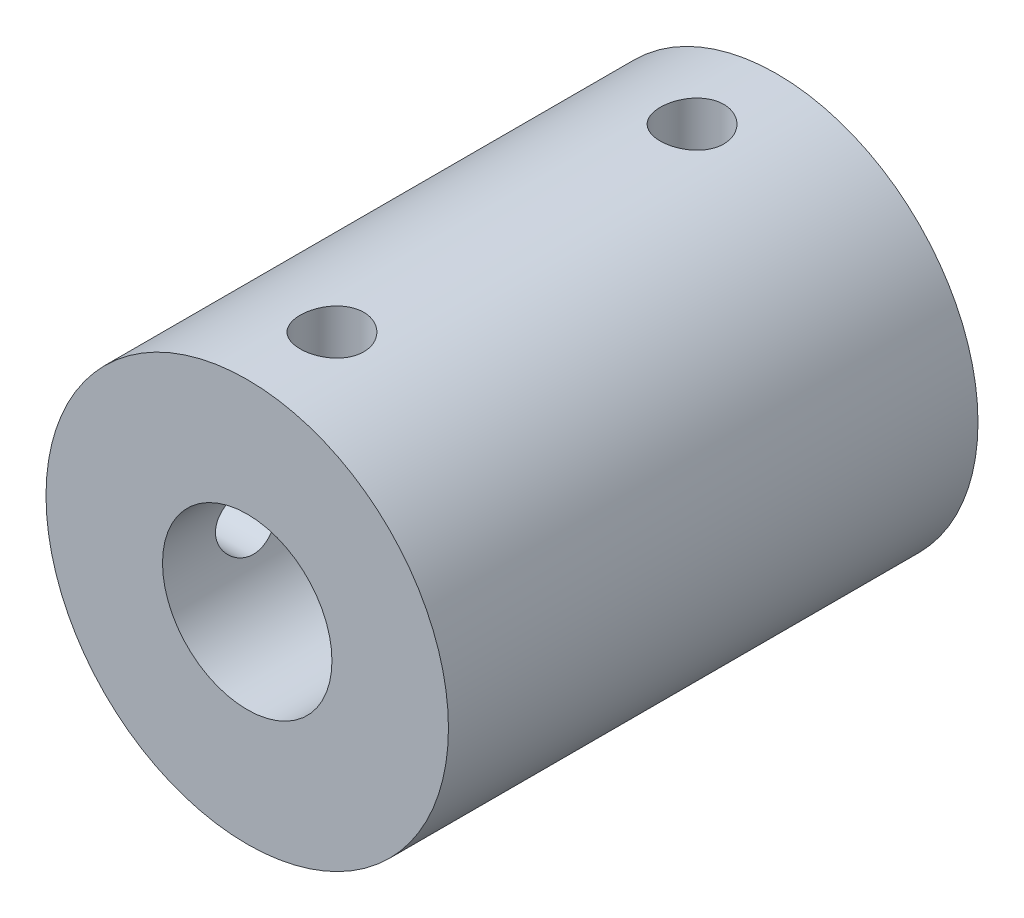
from build123d import *

# Parameters (mm, degrees)
ESBO_O1_R                = 9.5
RESSALTO_EXTRUS_O1_DEPTH = 25
ESBO_O2_R                = 4
CORTE_EXTRUS_O1_DEPTH    = 12.5
ESBO_O3_R                = 2.5
CORTE_EXTRUS_O2_DEPTH    = 26
ESBO_O4_R                = 1.5
CORTE_EXTRUS_O3_DEPTH    = 12
ESBO_O5_R                = 1.5
CORTE_EXTRUS_O4_DEPTH    = 10.5000001


with BuildPart() as part:
    # Esboço1 → Ressalto-extrusão1 (new body)
    with BuildSketch(Plane.XY):
        Circle(ESBO_O1_R)
    extrude(amount=RESSALTO_EXTRUS_O1_DEPTH)

    # Esboço2 → Corte-extrusão1 (cut)
    with BuildSketch(Plane.XY.offset(25)):
        Circle(ESBO_O2_R)
    extrude(amount=-CORTE_EXTRUS_O1_DEPTH, mode=Mode.SUBTRACT)

    # Esboço3 → Corte-extrusão2 (cut, through all)
    with BuildSketch(Plane(origin=(0, 0, 0), x_dir=(-1, 0, 0), z_dir=(0, 0, -1))):
        Circle(ESBO_O3_R)
    extrude(amount=-CORTE_EXTRUS_O2_DEPTH, mode=Mode.SUBTRACT)

    # Esboço4 → Corte-extrusão3 (cut)
    with BuildSketch(Plane(origin=(0, 0, 0), x_dir=(1, 0, 0), z_dir=(0, 1, 0))):
        with Locations((0, -4)):
            Circle(ESBO_O4_R)
        with Locations((0, -21)):
            Circle(ESBO_O4_R)
    extrude(amount=CORTE_EXTRUS_O3_DEPTH, mode=Mode.SUBTRACT)

    # Esboço5 → Corte-extrusão4 (cut, through all)
    with BuildSketch(Plane(origin=(0, 0, 0), x_dir=(0, 0, -1), z_dir=(1, 0, 0))):
        with Locations((-21, 0)):
            Circle(ESBO_O5_R)
        with Locations((-4, 0)):
            Circle(ESBO_O5_R)
    extrude(amount=-CORTE_EXTRUS_O4_DEPTH, mode=Mode.SUBTRACT)


solid = part.part
